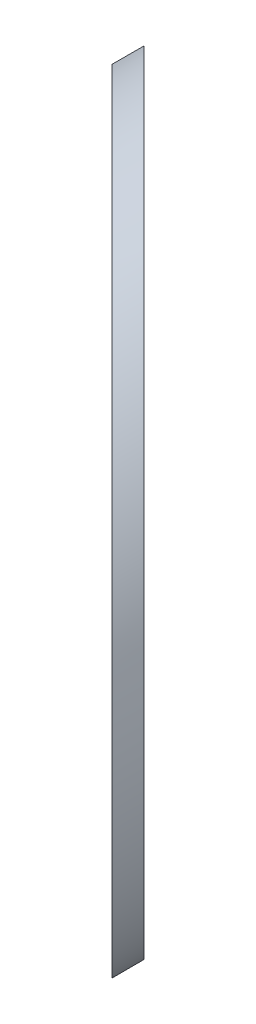
from build123d import *

# Parameters (mm, degrees)
SKETCH_1_R          = 12.5
EXTRUDE_1_DEPTH     = 61
CUT_EXTRUDE_1_DEPTH = 30.5


with BuildPart() as part:
    # 草图1 → 凸台-拉伸1 (new body)
    with BuildSketch(Plane.XY):
        Circle(SKETCH_1_R)
    extrude(amount=EXTRUDE_1_DEPTH)

    # 草图2 → 切除-拉伸1 (cut, symmetric)
    with BuildSketch(Plane(origin=(0, 0, 0), x_dir=(1, 0, 0), z_dir=(0, 1, 0))):
        Polygon((-39.378340461, 21.344490989), (32.946331, -50.980180473), (32.946331, 3.705336734), align=None)
        Polygon((-40.085447243, 20.637384208), (32.239224219, -51.687287254), (29.858688562, -63.951978102), (-29.50048748, -63.951978102), align=None)
    extrude(amount=CUT_EXTRUDE_1_DEPTH, both=True, mode=Mode.SUBTRACT)


solid = part.part
